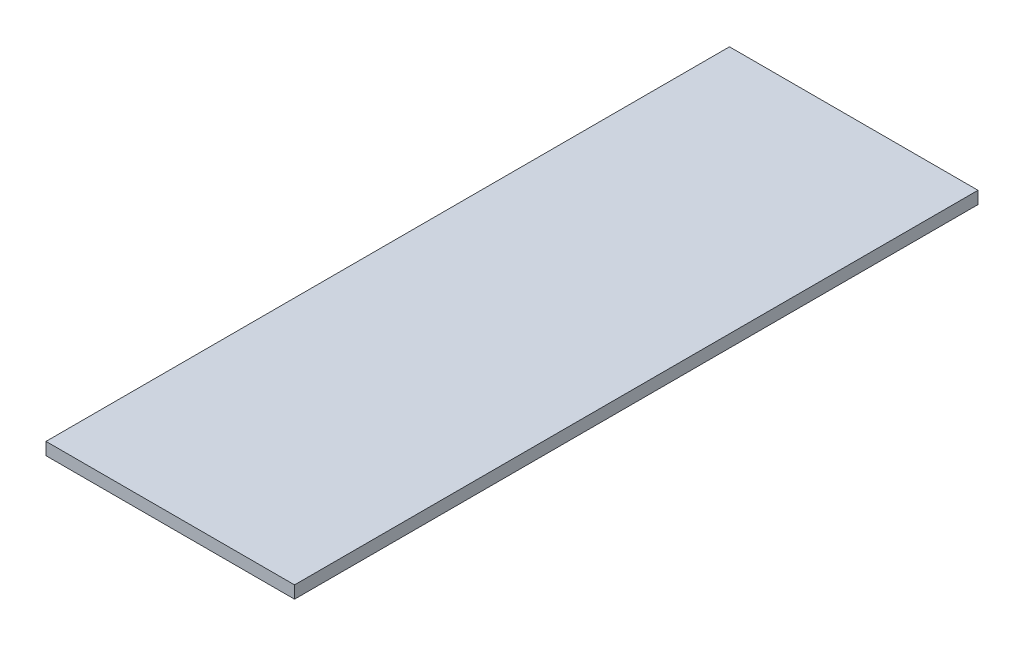
from build123d import *

# Parameters (mm, degrees)
SKETCH1_W           = 25.4
SKETCH1_H           = 69.85
BOSS_EXTRUDE1_DEPTH = 1.27


with BuildPart() as part:
    # Sketch1 → Boss-Extrude1 (new body)
    with BuildSketch(Plane(origin=(0, 0, 0), x_dir=(1, 0, 0), z_dir=(0, 1, 0))):
        Rectangle(SKETCH1_W, SKETCH1_H)
    extrude(amount=BOSS_EXTRUDE1_DEPTH)


solid = part.part
